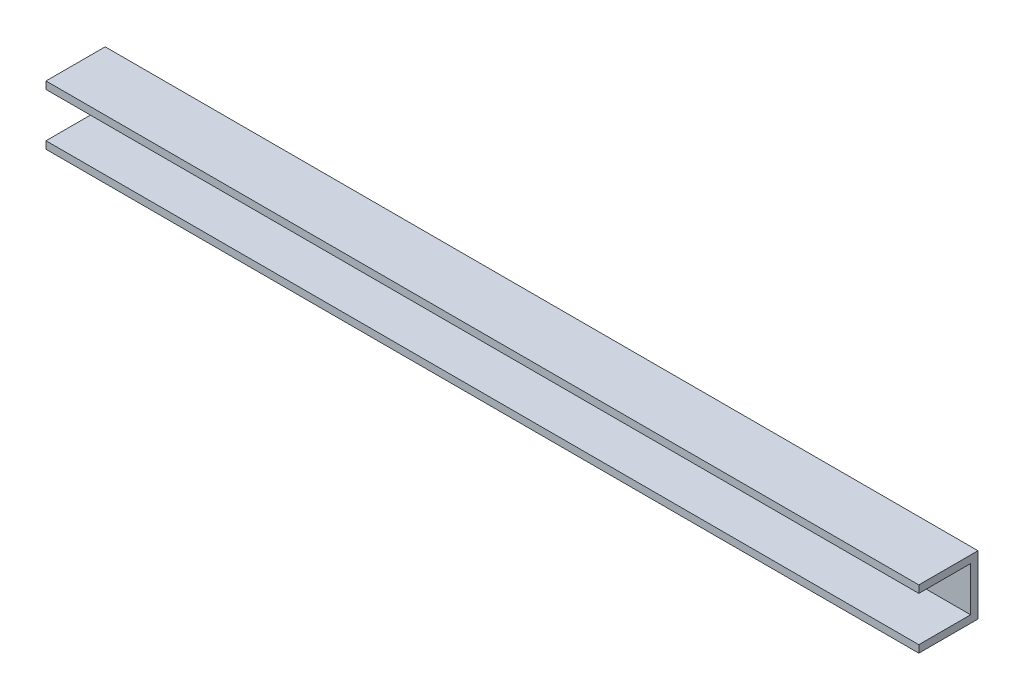
from build123d import *

# Parameters (mm, degrees)
SKETCH1_W           = 25.4
SKETCH1_H           = 25.4
BOSS_EXTRUDE1_DEPTH = 374.65
SKETCH2_R           = 6.35
CUT_EXTRUDE1_DEPTH  = 26.4
SKETCH3_W           = 22.225
SKETCH3_H           = 19.05
CUT_EXTRUDE2_DEPTH  = 375.65


with BuildPart() as part:
    # Sketch1 → Boss-Extrude1 (new body)
    with BuildSketch(Plane(origin=(0, 0, 0), x_dir=(0, 0, -1), z_dir=(1, 0, 0))):
        with Locations((12.7, 12.7)):
            Rectangle(SKETCH1_W, SKETCH1_H)
    extrude(amount=BOSS_EXTRUDE1_DEPTH)

    # Sketch2 → Cut-Extrude1 (cut, through all)
    with BuildSketch(Plane.XY):
        with Locations((187.325, 12.7)):
            Circle(SKETCH2_R)
    extrude(amount=-CUT_EXTRUDE1_DEPTH, mode=Mode.SUBTRACT)

    # Sketch3 → Cut-Extrude2 (cut, through all)
    with BuildSketch(Plane(origin=(374.65, 0, 0), x_dir=(0, 0, -1), z_dir=(1, 0, 0))):
        with Locations((11.1125, 12.7)):
            Rectangle(SKETCH3_W, SKETCH3_H)
    extrude(amount=-CUT_EXTRUDE2_DEPTH, mode=Mode.SUBTRACT)


solid = part.part
